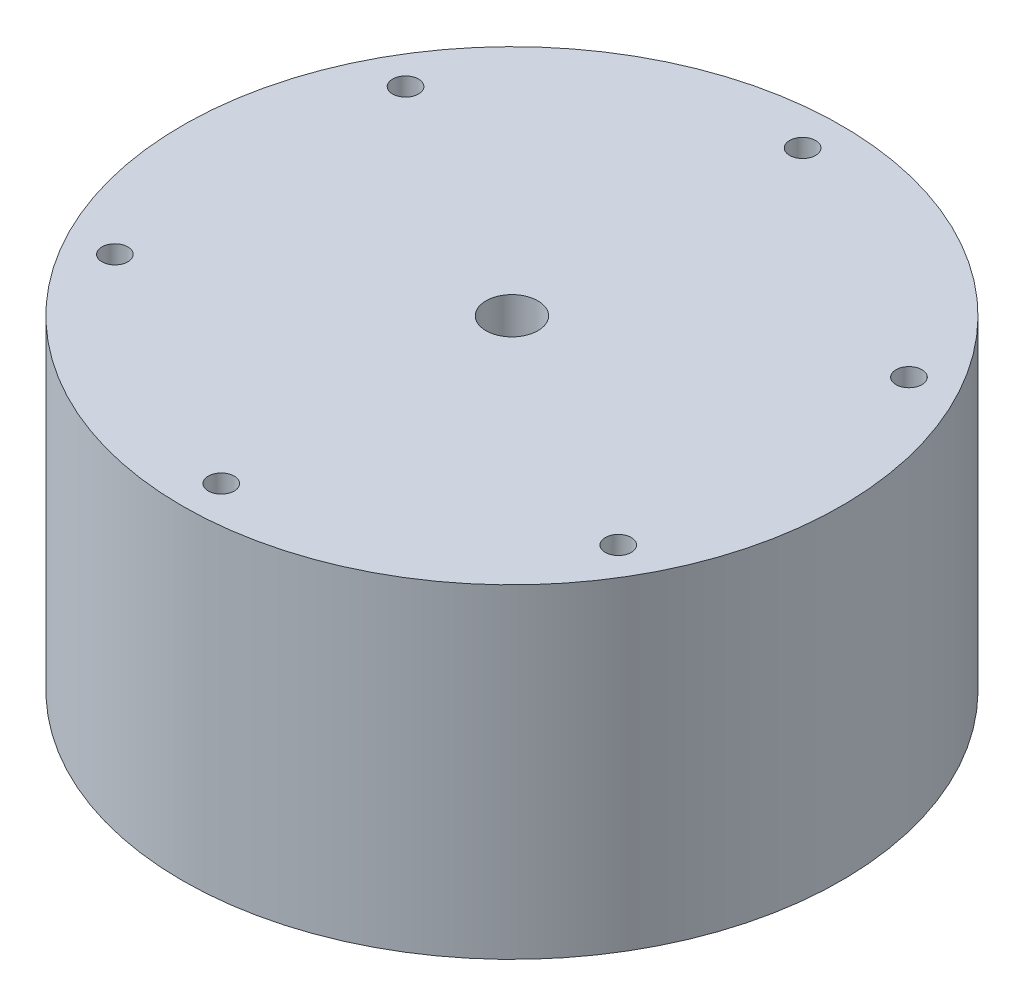
from build123d import *

# Parameters (mm, degrees)
SKETCH1_R           = 50.8
BOSS_EXTRUDE1_DEPTH = 50
SKETCH4_R           = 4
SKETCH4_R_2         = 2
CUT_EXTRUDE2_DEPTH  = 71


with BuildPart() as part:
    # Sketch1 → Boss-Extrude1 (new body)
    with BuildSketch(Plane(origin=(0, 0, 0), x_dir=(1, 0, 0), z_dir=(0, 1, 0))):
        Circle(SKETCH1_R)
    extrude(amount=BOSS_EXTRUDE1_DEPTH)

    # Sketch3 → Cut-Revolve1 (revolve, cut)
    with BuildSketch(Plane.XY):
        Polygon((0, 0), (38.1, 0), (38.1, 2), (36.5, 2), (0, 38.5), align=None)
    revolve(axis=Axis((0, 38.5, 0), (0, -1, 0)), mode=Mode.SUBTRACT)

    # Sketch4 → Cut-Extrude2 (cut)
    with BuildSketch(Plane(origin=(0, 50, 0), x_dir=(1, 0, 0), z_dir=(0, 1, 0))):
        Circle(SKETCH4_R)
        with Locations((0, 44.8)):
            Circle(SKETCH4_R_2)
        with Locations((38.79793809, 22.4)):
            Circle(SKETCH4_R_2)
        with Locations((38.79793809, -22.4)):
            Circle(SKETCH4_R_2)
        with Locations((0, -44.8)):
            Circle(SKETCH4_R_2)
        with Locations((-38.79793809, -22.4)):
            Circle(SKETCH4_R_2)
        with Locations((-38.79793809, 22.4)):
            Circle(SKETCH4_R_2)
    extrude(amount=-CUT_EXTRUDE2_DEPTH, mode=Mode.SUBTRACT)


solid = part.part
